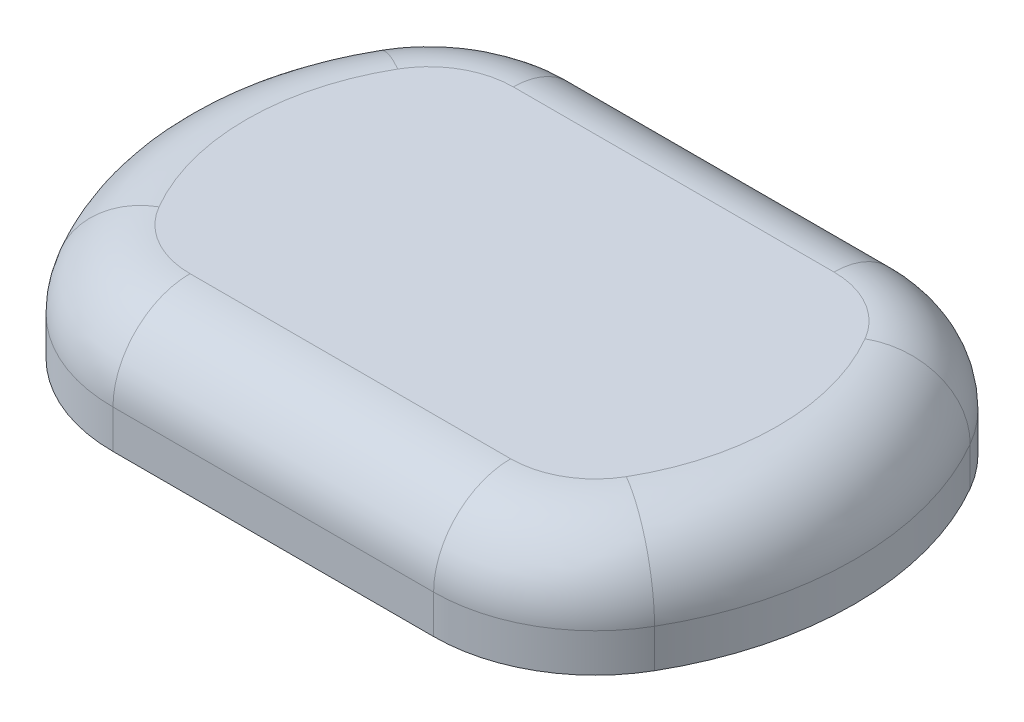
from build123d import *

# Parameters (mm, degrees)
SKETCH_1_W          = 89
SKETCH_1_H          = 62
EXTRUDE_1_DEPTH     = 15
CUT_EXTRUDE_START   = -15.000001
SKETCH_2_W          = 114.345269922
SKETCH_2_H          = 82.741202996
CUT_EXTRUDE_2_DEPTH = 15.000002
FILLET_1_R          = 10


with BuildPart() as part:
    # 草图1 → 凸台-拉伸1 (new body)
    with BuildSketch(Plane(origin=(0, 0, 0), x_dir=(1, 0, 0), z_dir=(0, 1, 0))):
        with Locations((-7.7, -10.288888889)):
            Rectangle(SKETCH_1_W, SKETCH_1_H)
    extrude(amount=EXTRUDE_1_DEPTH)

    # 草图2 → 切除-拉伸2 (cut)
    with BuildSketch(Plane(origin=(0, 15, 0), x_dir=(1, 0, 0), z_dir=(0, 1, 0)).offset(CUT_EXTRUDE_START)):
        with Locations((-11.341983823, -7.488413354)):
            Rectangle(SKETCH_2_W, SKETCH_2_H)
        with BuildLine():
            Line((-28.520508076, 20.711111111), (13.120508076, 20.711111111))
            ThreePointArc((13.120508076, 20.711111111), (23.620508076, 17.897644591), (31.307041555, 10.211111111))
            ThreePointArc((31.307041555, 10.211111111), (36.8, -10.288888889), (31.307041555, -30.788888889))
            ThreePointArc((31.307041555, -30.788888889), (23.620508076, -38.475422368), (13.120508076, -41.288888889))
            Line((13.120508076, -41.288888889), (-28.520508076, -41.288888889))
            ThreePointArc((-28.520508076, -41.288888889), (-39.020508076, -38.475422368), (-46.707041555, -30.788888889))
            ThreePointArc((-46.707041555, -30.788888889), (-52.2, -10.288888889), (-46.707041555, 10.211111111))
            ThreePointArc((-46.707041555, 10.211111111), (-39.020508076, 17.897644591), (-28.520508076, 20.711111111))
        make_face(mode=Mode.SUBTRACT)
    extrude(amount=CUT_EXTRUDE_2_DEPTH, mode=Mode.SUBTRACT)

    # 圆角1
    fillet_1_edges = [part.edges().sort_by_distance(p)[0] for p in [
        (23.620508076, 15, 38.475422368),
        (36.8, 15, 10.288888889),
        (-52.2, 15, 10.288888889),
        (-39.020508076, 15, -17.897644591),
        (-7.7, 15, 41.288888889),
        (-39.020508076, 15, 38.475422368),
        (-7.7, 15, -20.711111111),
        (23.620508076, 15, -17.897644591),
    ]]
    fillet(fillet_1_edges, radius=FILLET_1_R)


solid = part.part
